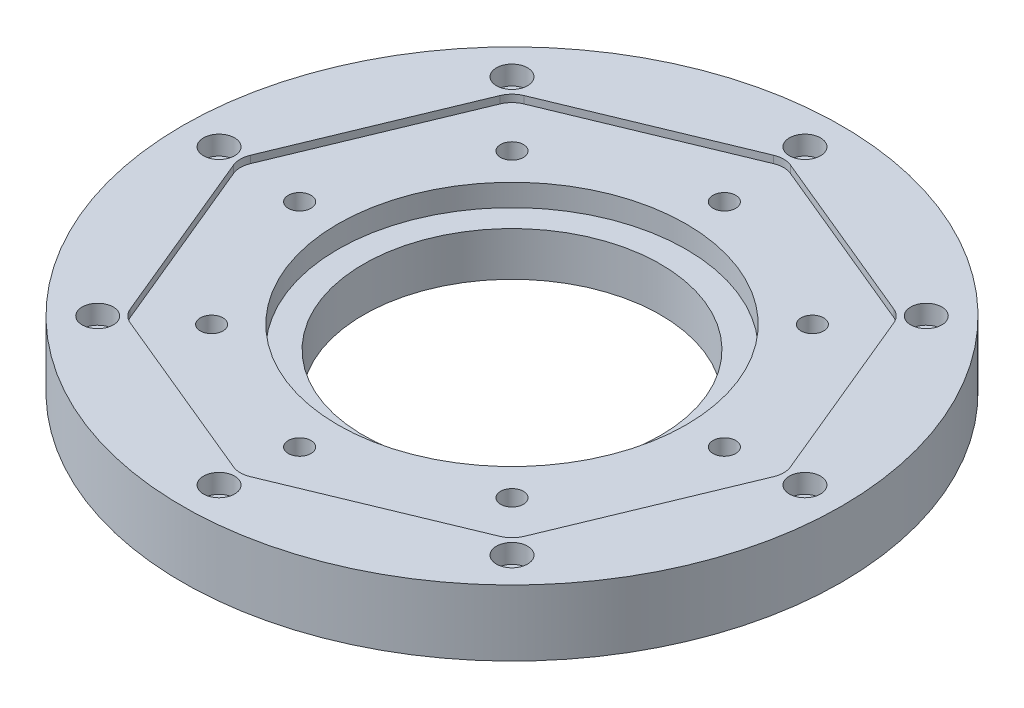
from build123d import *

# Parameters (mm, degrees)
ESQUISSE2_R             = 3.1
ENL_V_MAT_EXTRU_1_DEPTH = 21
ENL_V_MAT_EXTRU_2_DEPTH = 2
ESQUISSE4_R             = 2.6
ENL_V_MAT_EXTRU_3_DEPTH = 21
ESQUISSE5_R             = 4.25
ENL_V_MAT_EXTRU_4_DEPTH = 5.2
CONG_1_R                = 6


with BuildPart() as part:
    # Esquisse1 → Révolution1 (revolve)
    with BuildSketch(Plane.XY):
        Polygon((-40.55, 0), (-40.55, 12), (-47.55, 12), (-47.55, 20), (-65, 20), (-90, 20), (-90, 2), (-65, 2), (-65, 0), (-50.3, 0), (-50.3, 6), (-47.1, 6), (-47.1, 0), align=None)
    revolve(axis=Axis((0, 0, 0), (0, 1, 0)))

    # Esquisse2 → Enlèv. mat.-Extru.1 (cut, through all)
    with BuildSketch(Plane.XZ):
        with Locations((0, 58)):
            Circle(ESQUISSE2_R)
        with Locations((41.012193309, 41.012193309)):
            Circle(ESQUISSE2_R)
        with Locations((58, 0)):
            Circle(ESQUISSE2_R)
        with Locations((41.012193309, -41.012193309)):
            Circle(ESQUISSE2_R)
        with Locations((0, -58)):
            Circle(ESQUISSE2_R)
        with Locations((-41.012193309, -41.012193309)):
            Circle(ESQUISSE2_R)
        with Locations((-58, 0)):
            Circle(ESQUISSE2_R)
        with Locations((-41.012193309, 41.012193309)):
            Circle(ESQUISSE2_R)
    extrude(amount=-ENL_V_MAT_EXTRU_1_DEPTH, mode=Mode.SUBTRACT)

    # Esquisse3 → Enlèv. mat.-Extru.2 (cut)
    with BuildSketch(Plane(origin=(0, 20, 0), x_dir=(1, 0, 0), z_dir=(0, 1, 0))):
        Polygon((-52.810313666, 52.810313666), (-74.68506182, 0), (-52.810313666, -52.810313666), (0, -74.68506182), (52.810313666, -52.810313666), (74.68506182, 0), (52.810313666, 52.810313666), (0, 74.68506182), align=None)
    extrude(amount=-ENL_V_MAT_EXTRU_2_DEPTH, mode=Mode.SUBTRACT)

    # Esquisse4 → Enlèv. mat.-Extru.3 (cut, through all)
    with BuildSketch(Plane(origin=(0, 20, 0), x_dir=(1, 0, 0), z_dir=(0, 1, 0))):
        with Locations((0, 80)):
            Circle(ESQUISSE4_R)
        with Locations((56.568542495, 56.568542495)):
            Circle(ESQUISSE4_R)
        with Locations((80, 0)):
            Circle(ESQUISSE4_R)
        with Locations((56.568542495, -56.568542495)):
            Circle(ESQUISSE4_R)
        with Locations((0, -80)):
            Circle(ESQUISSE4_R)
        with Locations((-56.568542495, -56.568542495)):
            Circle(ESQUISSE4_R)
        with Locations((-80, 0)):
            Circle(ESQUISSE4_R)
        with Locations((-56.568542495, 56.568542495)):
            Circle(ESQUISSE4_R)
    extrude(amount=-ENL_V_MAT_EXTRU_3_DEPTH, mode=Mode.SUBTRACT)

    # Esquisse5 → Enlèv. mat.-Extru.4 (cut)
    with BuildSketch(Plane(origin=(0, 20, 0), x_dir=(1, 0, 0), z_dir=(0, 1, 0))):
        with Locations((0, 80)):
            Circle(ESQUISSE5_R)
        with Locations((56.568542495, 56.568542495)):
            Circle(ESQUISSE5_R)
        with Locations((80, 0)):
            Circle(ESQUISSE5_R)
        with Locations((56.568542495, -56.568542495)):
            Circle(ESQUISSE5_R)
        with Locations((0, -80)):
            Circle(ESQUISSE5_R)
        with Locations((-56.568542495, -56.568542495)):
            Circle(ESQUISSE5_R)
        with Locations((-80, 0)):
            Circle(ESQUISSE5_R)
        with Locations((-56.568542495, 56.568542495)):
            Circle(ESQUISSE5_R)
    extrude(amount=-ENL_V_MAT_EXTRU_4_DEPTH, mode=Mode.SUBTRACT)

    # Congé1
    cong_1_edges = [part.edges().sort_by_distance(p)[0] for p in [
        (-52.810313666, 19, 52.810313666),
        (-74.68506182, 19, 0),
        (-52.810313666, 19, -52.810313666),
        (0, 19, -74.68506182),
        (52.810313666, 19, -52.810313666),
        (74.68506182, 19, 0),
        (52.810313666, 19, 52.810313666),
        (0, 19, 74.68506182),
    ]]
    fillet(cong_1_edges, radius=CONG_1_R)


solid = part.part
